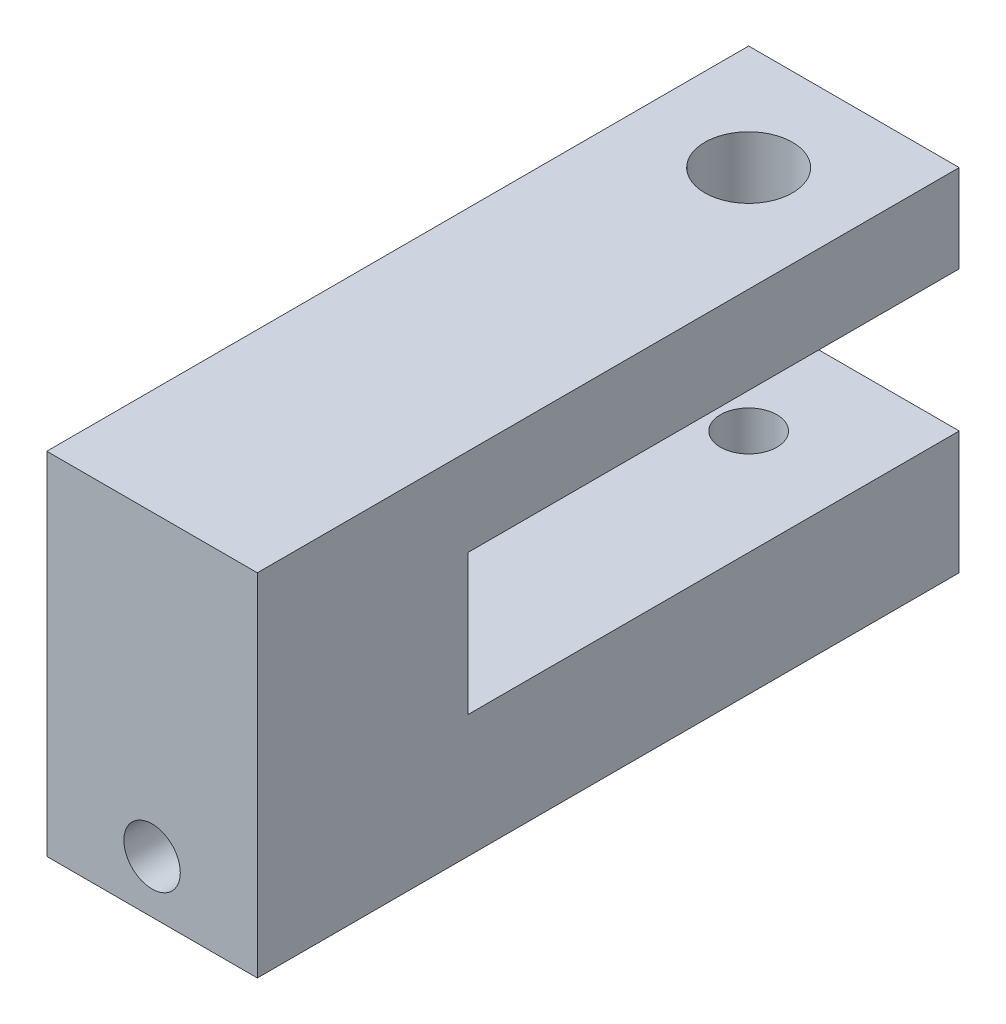
from build123d import *

# Parameters (mm, degrees)
BOSS_EXTRUDE1_DEPTH                = 9.525
F_1_4_20_TAPPED_HOLE1_D            = 5.1054
F_5_16_0_3125_DIAMETER_HOLE1_D     = 7.9375
F_5_16_0_3125_DIAMETER_HOLE1_DEPTH = 20.6365
F_1_4_20_TAPPED_HOLE2_D            = 5.1054
F_1_4_20_TAPPED_HOLE2_DEPTH        = 16.51
F_1_4_20_TAPPED_HOLE2_TIP          = 1.533816902


with BuildPart() as part:
    # Sketch3 → Boss-Extrude1 (new, symmetric)
    with BuildSketch(Plane(origin=(0, 0, 0), x_dir=(0, 0, -1), z_dir=(1, 0, 0))):
        Polygon((-53.975, 14.2875), (-53.975, -17.4625), (9.525, -17.4625), (9.525, -6.35), (-34.925, -6.35), (-34.925, 6.35), (9.525, 6.35), (9.525, 14.2875), align=None)
    extrude(amount=BOSS_EXTRUDE1_DEPTH, both=True)

    # 1/4-20 Tapped Hole1 (through all)
    with Locations(Plane(origin=(0, 14.2875, 0), x_dir=(1, 0, 0), z_dir=(0, 1, 0))):
        with Locations((0, 0)):
            Hole(F_1_4_20_TAPPED_HOLE1_D / 2)

    # 5/16 (0.3125) Diameter Hole1
    with Locations(Plane(origin=(0, 14.2875, 0), x_dir=(1, 0, 0), z_dir=(0, 1, 0))):
        with Locations((0, 0)):
            Hole(F_5_16_0_3125_DIAMETER_HOLE1_D / 2, depth=F_5_16_0_3125_DIAMETER_HOLE1_DEPTH)

    # 1/4-20 Tapped Hole2
    with Locations(Plane.XY.offset(53.975)):
        with Locations((0, -12.7)):
            Hole(F_1_4_20_TAPPED_HOLE2_D / 2, depth=F_1_4_20_TAPPED_HOLE2_DEPTH)
            with Locations((0, 0, -(F_1_4_20_TAPPED_HOLE2_DEPTH + F_1_4_20_TAPPED_HOLE2_TIP / 2))):  # 118° drill point
                Cone(0, F_1_4_20_TAPPED_HOLE2_D / 2, F_1_4_20_TAPPED_HOLE2_TIP, mode=Mode.SUBTRACT)


solid = part.part
